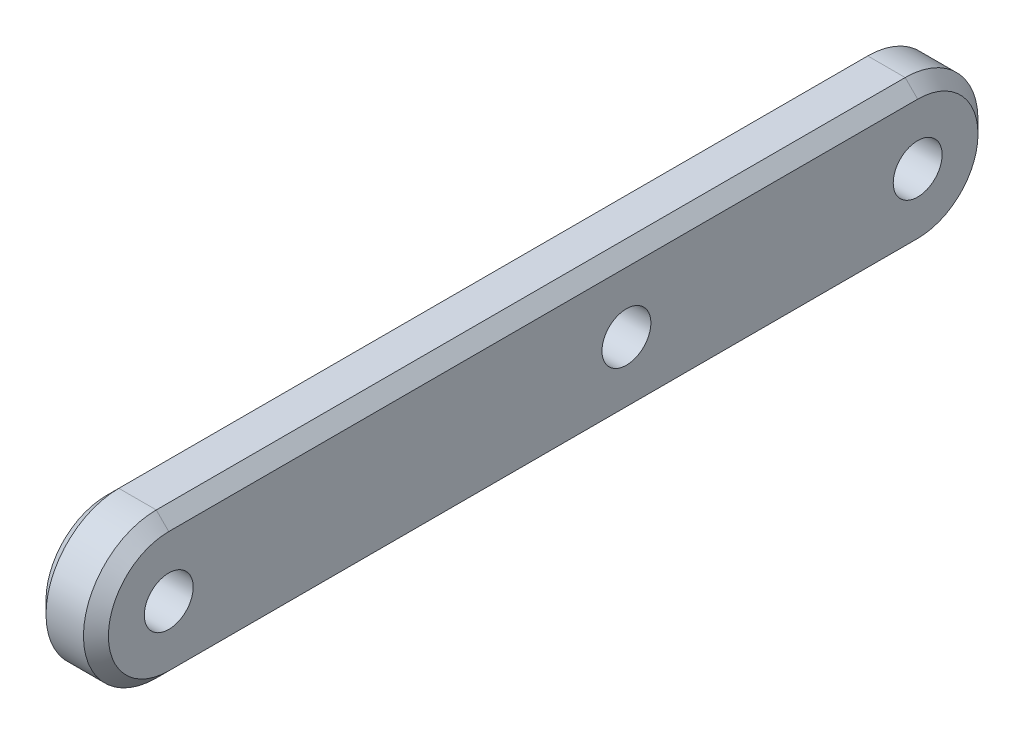
from build123d import *

# Parameters (mm, degrees)
SKETCH_1_R               = 0.85
EXTRUDE_1_DEPTH          = 1.5
SKETCH_3_R               = 1.175
CUT_EXTRUDE_2_DEPTH      = 1
CUT_EXTRUDE_2_DEPTH_BACK = 4
CHAMFER_1_SIZE           = 0.6


with BuildPart() as part:
    # 草图1 → 凸台-拉伸1 (new body, symmetric)
    with BuildSketch(Plane(origin=(0, 0, 0), x_dir=(0, 0, -1), z_dir=(1, 0, 0))):
        with BuildLine():
            Line((-18, 3.5), (18, 3.5))
            ThreePointArc((18, 3.5), (21.5, 0), (18, -3.5))
            Line((18, -3.5), (-18, -3.5))
            ThreePointArc((-18, -3.5), (-21.5, 0), (-18, 3.5))
        make_face()
        with Locations((18, 0)):
            Circle(SKETCH_1_R, mode=Mode.SUBTRACT)
        with Locations((4, 0)):
            Circle(SKETCH_1_R, mode=Mode.SUBTRACT)
        with Locations((-18, 0)):
            Circle(SKETCH_1_R, mode=Mode.SUBTRACT)
    extrude(amount=EXTRUDE_1_DEPTH, both=True)

    # 草图3 → 切除-拉伸2 (cut, two sides)
    with BuildSketch(Plane.ZY.offset(1.5)) as cut_extrude_2_sk:
        with Locations((-18, 0)):
            Circle(SKETCH_3_R)
        with Locations((-4, 0)):
            Circle(SKETCH_3_R)
        with Locations((18, 0)):
            Circle(SKETCH_3_R)
    extrude(amount=CUT_EXTRUDE_2_DEPTH, mode=Mode.SUBTRACT)
    extrude(cut_extrude_2_sk.sketch, amount=-CUT_EXTRUDE_2_DEPTH_BACK, mode=Mode.SUBTRACT)

    # 倒角1
    chamfer_1_edges = [part.edges().sort_by_distance(p)[0] for p in [
        (1.5, 0, -21.5),
        (1.5, 3.5, 0),
        (1.5, 0, 21.5),
        (-1.5, 3.5, 0),
        (-1.5, 0, -21.5),
        (-1.5, -3.5, 0),
        (-1.5, 0, 21.5),
        (1.5, -3.5, 0),
    ]]
    chamfer(chamfer_1_edges, length=CHAMFER_1_SIZE)


solid = part.part
